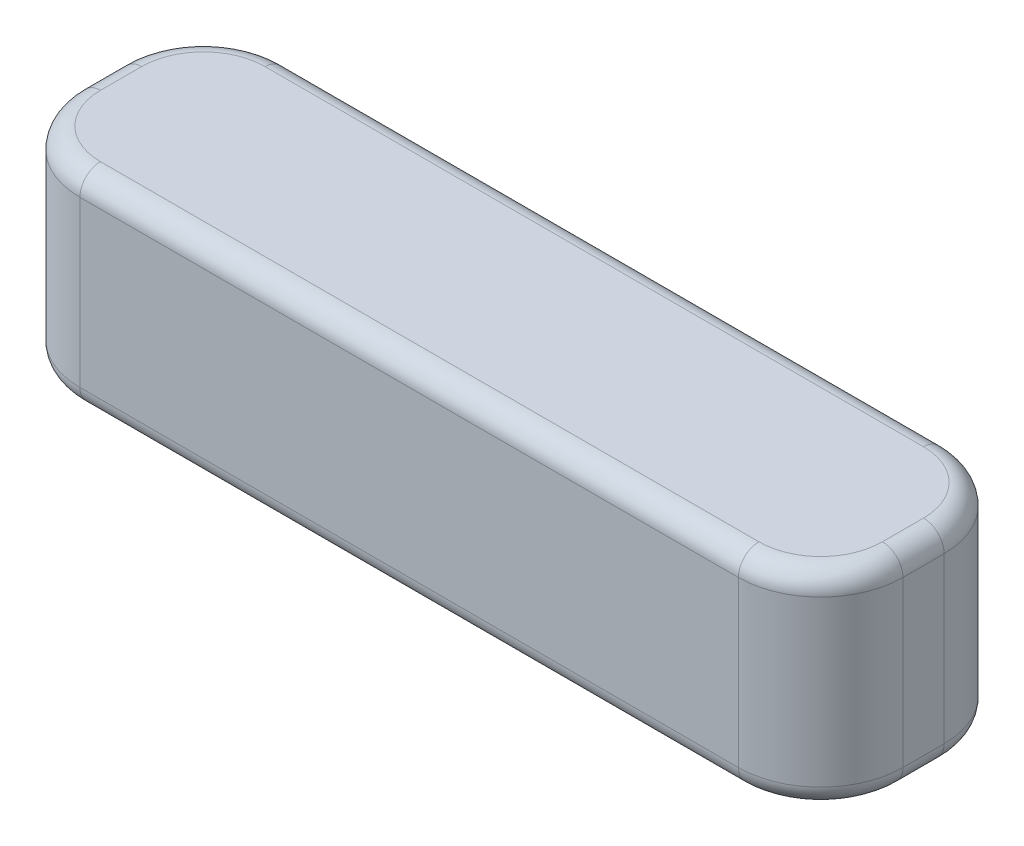
from build123d import *

# Parameters (mm, degrees)
SKETCH_1_W      = 20
SKETCH_1_H      = 5
EXTRUDE_1_DEPTH = 5
FILLET_1_R      = 2
FILLET_2_R      = 0.5


with BuildPart() as part:
    # 草圖1 → 填料-伸長1 (new body)
    with BuildSketch(Plane(origin=(0, 0, 0), x_dir=(1, 0, 0), z_dir=(0, 1, 0))):
        Rectangle(SKETCH_1_W, SKETCH_1_H)
    extrude(amount=EXTRUDE_1_DEPTH)

    # 圓角1
    fillet_1_edges = [part.edges().sort_by_distance(p)[0] for p in [
        (10, 2.5, 2.5),
        (-10, 2.5, 2.5),
        (-10, 2.5, -2.5),
        (10, 2.5, -2.5),
    ]]
    fillet(fillet_1_edges, radius=FILLET_1_R)

    # 圓角2
    fillet_2_edges = [part.edges().sort_by_distance(p)[0] for p in [
        (-10, 0, 0),
        (-10, 5, 0),
        (10, 0, 0),
        (0, 0, 2.5),
        (0, 0, -2.5),
        (9.414213562, 0, -1.914213562),
        (9.414213562, 0, 1.914213562),
        (-9.414213562, 0, 1.914213562),
        (-9.414213562, 0, -1.914213562),
        (0, 5, -2.5),
        (10, 5, 0),
        (0, 5, 2.5),
        (9.414213562, 5, -1.914213562),
        (9.414213562, 5, 1.914213562),
        (-9.414213562, 5, 1.914213562),
        (-9.414213562, 5, -1.914213562),
    ]]
    fillet(fillet_2_edges, radius=FILLET_2_R)


solid = part.part
